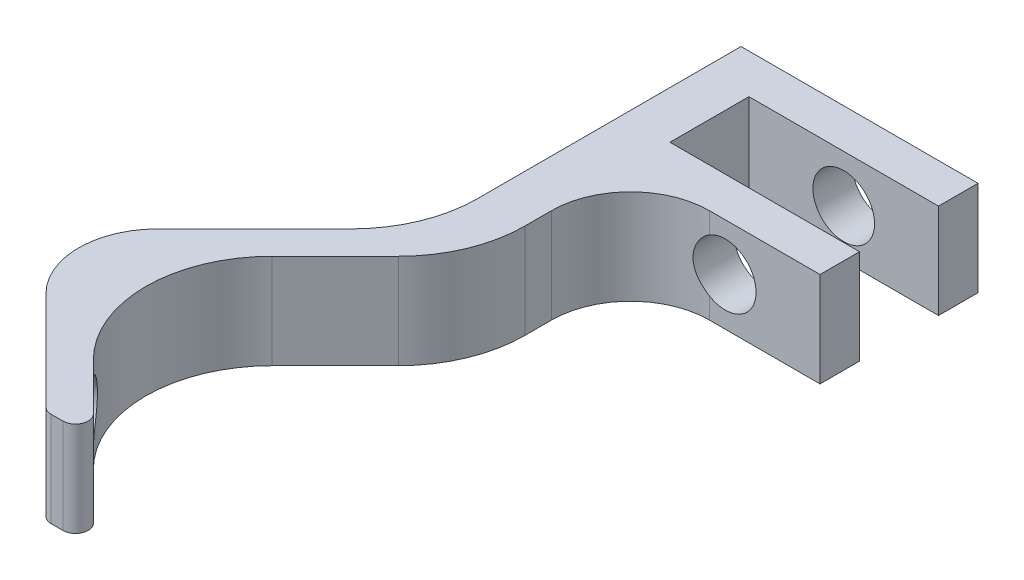
from build123d import *

# Parameters (mm, degrees)
SALIENTE_EXTRUIR1_DEPTH    = 6
REDONDEO1_R                = 8
REDONDEO2_R                = 5
REDONDEO3_R                = 8
REDONDEO4_R                = 0.8
CORTAR_EXTRUIR1_DEPTH      = 6
CORTAR_EXTRUIR1_DEPTH_BACK = 6
CROQUIS2_R                 = 1.9
REDONDEO5_R                = 5
CORTAR_EXTRUIR2_DEPTH      = 39.095275313
CORTAR_EXTRUIR2_DEPTH_BACK = 10
CROQUIS3_R                 = 1.95


with BuildPart() as part:
    # Croquis1 → Saliente-Extruir1 (new body)
    with BuildSketch(Plane(origin=(0, 0, 0), x_dir=(1, 0, 0), z_dir=(0, 1, 0))):
        Polygon((0, 20), (0, 0), (-12, -12), (-2, -22), (1, -22), (-9, -12), (3, 0), (3, 10), (15, 10), (15, 12.5), (3, 12.5), (3, 17.5), (15, 17.5), (15, 20), align=None)
    extrude(amount=SALIENTE_EXTRUIR1_DEPTH)

    # Redondeo1
    redondeo1_edges = [part.edges().sort_by_distance(p)[0] for p in [
        (-9, 3, 12),
    ]]
    fillet(redondeo1_edges, radius=REDONDEO1_R)

    # Redondeo2
    redondeo2_edges = [part.edges().sort_by_distance(p)[0] for p in [
        (-12, 3, 12),
    ]]
    fillet(redondeo2_edges, radius=REDONDEO2_R)

    # Redondeo3
    redondeo3_edges = [part.edges().sort_by_distance(p)[0] for p in [
        (0, 3, 0),
        (3, 3, 0),
    ]]
    fillet(redondeo3_edges, radius=REDONDEO3_R)

    # Redondeo4
    redondeo4_edges = [part.edges().sort_by_distance(p)[0] for p in [
        (-2, 3, 22),
        (1, 3, 22),
    ]]
    fillet(redondeo4_edges, radius=REDONDEO4_R)

    # Croquis2 → Cortar-Extruir1 (cut, two sides: drawn at the far end of the back side and taken through both)
    with BuildSketch(Plane(origin=(-10.5, 0, 10.5), x_dir=(-0.7071067811865541, 0, -0.7071067811865409), z_dir=(0.7071067811865409, 0, -0.7071067811865541)).offset(-CORTAR_EXTRUIR1_DEPTH_BACK)):
        with Locations((-10.332085117, 3)):
            Circle(CROQUIS2_R)
    extrude(amount=CORTAR_EXTRUIR1_DEPTH + CORTAR_EXTRUIR1_DEPTH_BACK, mode=Mode.SUBTRACT)

    # Redondeo5
    redondeo5_edges = [part.edges().sort_by_distance(p)[0] for p in [
        (3, 3, -10),
    ]]
    fillet(redondeo5_edges, radius=REDONDEO5_R)

    # Croquis3 → Cortar-Extruir2 (cut, two sides: drawn at the far end of the back side and taken through both)
    with BuildSketch(Plane(origin=(0, 0, -12.5), x_dir=(-1, 0, 0), z_dir=(0, 0, -1)).offset(-CORTAR_EXTRUIR2_DEPTH_BACK)):
        with Locations((-9, 3)):
            Circle(CROQUIS3_R)
    extrude(amount=CORTAR_EXTRUIR2_DEPTH + CORTAR_EXTRUIR2_DEPTH_BACK, mode=Mode.SUBTRACT)


solid = part.part
